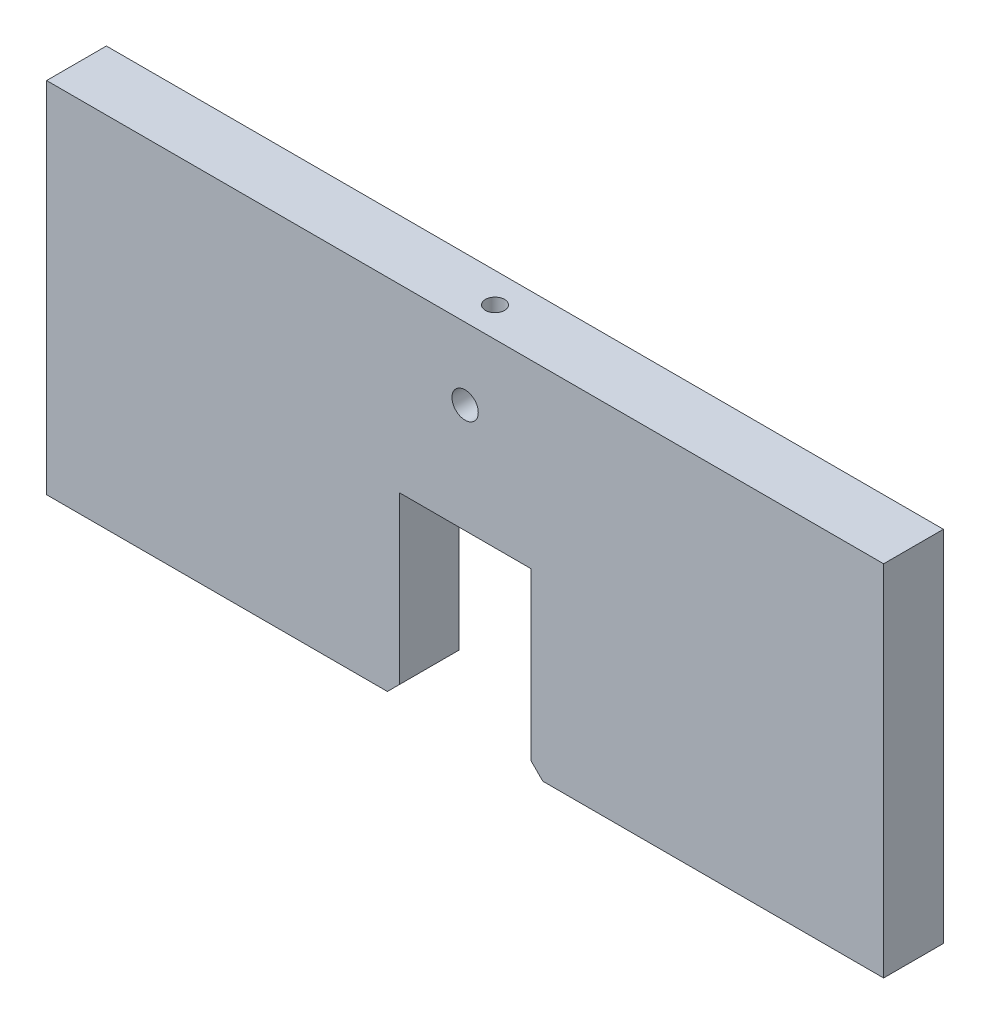
from build123d import *

# Parameters (mm, degrees)
BOSS_EXTRUDE1_DEPTH     = 25
SKETCH2_R               = 11
CUT_EXTRUDE1_DEPTH      = 26
CUT_EXTRUDE1_DEPTH_BACK = 26
SKETCH3_R               = 8
CUT_EXTRUDE2_DEPTH      = 35
SKETCH4_R               = 8
CUT_EXTRUDE3_DEPTH      = 30


with BuildPart() as part:
    # Sketch1 → Boss-Extrude1 (new body, symmetric)
    with BuildSketch(Plane.XY):
        Polygon((350, 232.421392473), (-350, 232.421392473), (-350, -67.578607527), (-65, -67.578607527), (-55, -57.578607527), (-55, 81.421392473), (55, 81.421392473), (55, -57.578607527), (65, -67.578607527), (350, -67.578607527), align=None)
    extrude(amount=BOSS_EXTRUDE1_DEPTH, both=True)

    # Sketch2 → Cut-Extrude1 (cut, two sides)
    with BuildSketch(Plane.XY) as cut_extrude1_sk:
        with Locations((0, 172.421392473)):
            Circle(SKETCH2_R)
    extrude(amount=CUT_EXTRUDE1_DEPTH, mode=Mode.SUBTRACT)
    extrude(cut_extrude1_sk.sketch, amount=-CUT_EXTRUDE1_DEPTH_BACK, mode=Mode.SUBTRACT)

    # Sketch3 → Cut-Extrude2 (cut)
    with BuildSketch(Plane(origin=(0, 232.421392473, 0), x_dir=(1, 0, 0), z_dir=(0, 1, 0))):
        Circle(SKETCH3_R)
    extrude(amount=-CUT_EXTRUDE2_DEPTH, mode=Mode.SUBTRACT)

    # Sketch4 → Cut-Extrude3 (cut)
    with BuildSketch(Plane.XZ.offset(67.578607527)):
        with Locations((-80, 0)):
            Circle(SKETCH4_R)
        with Locations((80, 0)):
            Circle(SKETCH4_R)
    extrude(amount=-CUT_EXTRUDE3_DEPTH, mode=Mode.SUBTRACT)


solid = part.part
